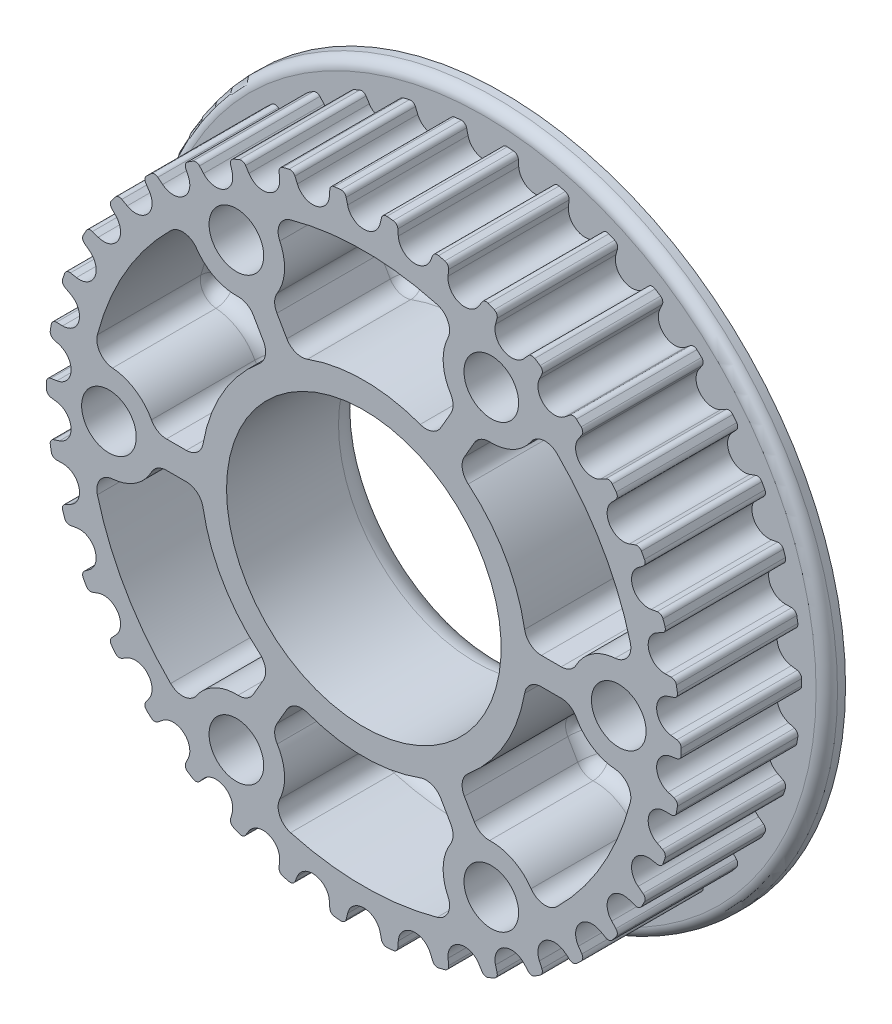
from build123d import *

# Parameters (mm, degrees)
SKETCH1_W                      = 32
SKETCH1_H                      = 1.75
BOSS_EXTRUDE1_DEPTH            = 11.25
CUT_EXTRUDE1_DEPTH             = 11.25
CUT_EXTRUDE2_DEPTH             = 11.25
CUT_EXTRUDE3_DEPTH             = 11.25
CUT_EXTRUDE4_DEPTH             = 11.25
CUT_EXTRUDE5_DEPTH             = 11.25
CUT_EXTRUDE6_DEPTH             = 11.25
F_7_0_201_DIAMETER_HOLE1_D     = 5.1054
F_7_0_201_DIAMETER_HOLE1_DEPTH = 13
HOLE1_D                        = 25.654
HOLE1_DEPTH                    = 13
FILLET1_R                      = 0.48
FILLET2_R                      = 1
FILLET3_R                      = 1.5875
FILLET4_R                      = 2.54


with BuildPart() as part:
    # Sketch1 → Revolve1 (revolve)
    with BuildSketch(Plane(origin=(0, 0, 0), x_dir=(1, 0, 0), z_dir=(0, 1, 0))):
        with Locations((16, 0.875)):
            Rectangle(SKETCH1_W, SKETCH1_H)
    revolve(axis=Axis((0, 0, -1.75), (0, 0, 1)))

    # Sketch2 → Boss-Extrude1 (add)
    with BuildSketch(Plane.XY):
        with BuildLine():
            Line((7.961201337, 28.561193485), (7.86683106, 27.588854508))
            ThreePointArc((7.86683106, 27.588854508), (8.913003864, 25.962682106), (10.737397135, 26.603387505))
            Line((10.737397135, 26.603387505), (11.260148905, 27.428662866))
            ThreePointArc((11.260148905, 27.428662866), (11.910272883, 27.152677582), (12.553638769, 26.861285406))
            Line((12.553638769, 26.861285406), (12.300513847, 25.917740702))
            ThreePointArc((12.300513847, 25.917740702), (13.064759044, 24.14155279), (14.96972661, 24.473234547))
            Line((14.96972661, 24.473234547), (15.621184585, 25.201212117))
            ThreePointArc((15.621184585, 25.201212117), (16.217016035, 24.821984025), (16.803645674, 24.428671516))
            Line((16.803645674, 24.428671516), (16.398670696, 23.539658523))
            ThreePointArc((16.398670696, 23.539658523), (16.86014167, 21.661904877), (18.793720984, 21.675515578))
            Line((18.793720984, 21.675515578), (19.556115089, 22.286338027))
            ThreePointArc((19.556115089, 22.286338027), (20.081401284, 21.81421148), (20.59529295, 21.329707178))
            Line((20.59529295, 21.329707178), (20.049514576, 20.519475852))
            ThreePointArc((20.049514576, 20.519475852), (20.195623602, 18.591376692), (22.105071664, 18.286545073))
            Line((22.105071664, 18.286545073), (22.957605776, 18.763550758))
            ThreePointArc((22.957605776, 18.763550758), (23.398018278, 18.211404137), (23.825154347, 17.648924056))
            Line((23.825154347, 17.648924056), (23.153459988, 16.939575394))
            ThreePointArc((23.153459988, 16.939575394), (22.980221594, 15.013724238), (24.813453639, 14.398765311))
            Line((24.813453639, 14.398765311), (25.732872851, 14.72894276))
            ThreePointArc((25.732872851, 14.72894276), (26.076398357, 14.111837185), (26.40512767, 13.486724314))
            Line((26.40512767, 13.486724314), (25.625839397, 12.897607499))
            ThreePointArc((25.625839397, 12.897607499), (25.137979073, 11.026536543), (26.844989313, 10.118224783))
            Line((26.844989313, 10.118224783), (27.806214267, 10.292567617))
            ThreePointArc((27.806214267, 10.292567617), (28.043482295, 9.627336119), (28.264837975, 8.956641907))
            Line((28.264837975, 8.956641907), (27.399212739, 8.503826508))
            ThreePointArc((27.399212739, 8.503826508), (26.610038043, 6.738573689), (28.144263691, 5.561685471))
            Line((28.144263691, 5.561685471), (29.121074676, 5.575438073))
            ThreePointArc((29.121074676, 5.575438073), (29.245613175, 4.880226432), (29.353557215, 4.182245667))
            Line((29.353557215, 4.182245667), (28.425207015, 3.878083308))
            ThreePointArc((28.425207015, 3.878083308), (27.356244575, 2.266800118), (28.675835956, 0.853437885))
            Line((28.675835956, 0.853437885), (29.641588117, 0.706225118))
            ThreePointArc((29.641588117, 0.706225118), (29.65, -3.105e-06), (29.641587969, -0.706231327))
            Line((29.641587969, -0.706231327), (28.675835777, -0.853443891))
            ThreePointArc((28.675835777, -0.853443891), (27.3562441, -2.266805848), (28.425206203, -3.878089261))
            Line((28.425206203, -3.878089261), (29.353556339, -4.182251815))
            ThreePointArc((29.353556339, -4.182251815), (29.245612153, -4.880232557), (29.121073509, -5.575444172))
            Line((29.121073509, -5.575444172), (28.144262526, -5.561691366))
            ThreePointArc((28.144262526, -5.561691366), (26.610036632, -6.738579262), (27.399210958, -8.503832246))
            Line((27.399210958, -8.503832246), (28.264836099, -8.956647827))
            ThreePointArc((28.264836099, -8.956647827), (28.043480279, -9.627341993), (27.806212111, -10.292573441))
            Line((27.806212111, -10.292573441), (26.844987194, -10.118230405))
            ThreePointArc((26.844987194, -10.118230405), (25.137976763, -11.026541808), (25.625836695, -12.897612866))
            Line((25.625836695, -12.897612866), (26.405124845, -13.486729844))
            ThreePointArc((26.405124845, -13.486729844), (26.076395401, -14.111842647), (25.732869766, -14.72894815))
            Line((25.732869766, -14.72894815), (24.813450624, -14.398770508))
            ThreePointArc((24.813450624, -14.398770508), (22.980218449, -15.013729051), (23.153456441, -16.939580244))
            Line((23.153456441, -16.939580244), (23.825150651, -17.648929046))
            ThreePointArc((23.825150651, -17.648929046), (23.398014464, -18.211409038), (22.957601846, -18.763555566))
            Line((22.957601846, -18.763555566), (22.105067834, -18.286549703))
            ThreePointArc((22.105067834, -18.286549703), (20.195619708, -18.591380922), (20.049510279, -20.519480051))
            Line((20.049510279, -20.519480051), (20.595288483, -21.329711491))
            ThreePointArc((20.595288483, -21.329711491), (20.081396715, -21.814215685), (19.556110421, -22.286342122))
            Line((19.556110421, -22.286342122), (18.793716444, -21.675519514))
            ThreePointArc((18.793716444, -21.675519514), (16.860137133, -21.661908408), (16.398665766, -23.539661958))
            Line((16.398665766, -23.539661958), (16.803640558, -24.428675036))
            ThreePointArc((16.803640558, -24.428675036), (16.217010836, -24.821987421), (15.621179306, -25.201215389))
            Line((15.621179306, -25.201215389), (14.969721484, -24.473237683))
            ThreePointArc((14.969721484, -24.473237683), (13.064753987, -24.141555527), (12.300508419, -25.917743278))
            Line((12.300508419, -25.917743278), (12.553633143, -26.861288035))
            ThreePointArc((12.553633143, -26.861288035), (11.910267196, -27.152680076), (11.260143161, -27.428665225))
            Line((11.260143161, -27.428665225), (10.737391563, -26.603389754))
            ThreePointArc((10.737391563, -26.603389754), (8.912998426, -25.962683972), (7.866825282, -27.588856155))
            Line((7.866825282, -27.588856155), (7.961195356, -28.561195152))
            ThreePointArc((7.961195356, -28.561195152), (7.278642529, -28.742718433), (6.591959676, -28.907932607))
            Line((6.591959676, -28.907932607), (6.212173604, -28.007870735))
            ThreePointArc((6.212173604, -28.007870735), (4.518119513, -27.07561811), (3.218555668, -28.507416989))
            Line((3.218555668, -28.507416989), (3.151596922, -29.482027353))
            ThreePointArc((3.151596922, -29.482027353), (2.448475476, -29.548730393), (1.743964724, -29.598666981))
            Line((1.743964724, -29.598666981), (1.51750375, -28.648370047))
            ThreePointArc((1.51750375, -28.648370047), (-1.916e-06, -27.45), (-1.51750775, -28.648369835))
            Line((-1.51750775, -28.648369835), (-1.743968856, -29.598666737))
            ThreePointArc((-1.743968856, -29.598666737), (-2.448479602, -29.548730051), (-3.151601038, -29.482026913))
            Line((-3.151601038, -29.482026913), (-3.218559649, -28.50741654))
            ThreePointArc((-3.218559649, -28.50741654), (-4.518123294, -27.07561748), (-6.212177514, -28.007869867))
            Line((-6.212177514, -28.007869867), (-6.591963712, -28.907931687))
            ThreePointArc((-6.591963712, -28.907931687), (-7.278646542, -28.742717417), (-7.961199344, -28.56119404))
            Line((-7.961199344, -28.56119404), (-7.866829134, -27.588855057))
            ThreePointArc((-7.866829134, -27.588855057), (-8.913002051, -25.962682728), (-10.737395278, -26.603388255))
            Line((-10.737395278, -26.603388255), (-11.26014699, -27.428663652))
            ThreePointArc((-11.26014699, -27.428663652), (-11.910270987, -27.152678413), (-12.553636893, -26.861286282))
            Line((-12.553636893, -26.861286282), (-12.300512038, -25.91774156))
            ThreePointArc((-12.300512038, -25.91774156), (-13.064757358, -24.141553703), (-14.969724901, -24.473235592))
            Line((-14.969724901, -24.473235592), (-15.621182825, -25.201213208))
            ThreePointArc((-15.621182825, -25.201213208), (-16.217014302, -24.821985157), (-16.803643969, -24.428672689))
            Line((-16.803643969, -24.428672689), (-16.398669053, -23.539659668))
            ThreePointArc((-16.398669053, -23.539659668), (-16.860140157, -21.661906054), (-18.793719471, -21.67551689))
            Line((-18.793719471, -21.67551689), (-19.556113533, -22.286339392))
            ThreePointArc((-19.556113533, -22.286339392), (-20.081399761, -21.814212882), (-20.595291461, -21.329708616))
            Line((-20.595291461, -21.329708616), (-20.049513144, -20.519477251))
            ThreePointArc((-20.049513144, -20.519477251), (-20.195622304, -18.591378102), (-22.105070387, -18.286546616))
            Line((-22.105070387, -18.286546616), (-22.957604466, -18.763552361))
            ThreePointArc((-22.957604466, -18.763552361), (-23.398017007, -18.211405771), (-23.825153115, -17.648925719))
            Line((-23.825153115, -17.648925719), (-23.153458806, -16.939577011))
            ThreePointArc((-23.153458806, -16.939577011), (-22.980220545, -15.013725843), (-24.813452634, -14.398767043))
            Line((-24.813452634, -14.398767043), (-25.732871823, -14.728944557))
            ThreePointArc((-25.732871823, -14.728944557), (-26.076397371, -14.111839006), (-26.405126729, -13.486726158))
            Line((-26.405126729, -13.486726158), (-25.625838496, -12.897609288))
            ThreePointArc((-25.625838496, -12.897609288), (-25.137978303, -11.026538298), (-26.844988607, -10.118226657))
            Line((-26.844988607, -10.118226657), (-27.806213548, -10.292569558))
            ThreePointArc((-27.806213548, -10.292569558), (-28.043481623, -9.627338077), (-28.26483735, -8.95664388))
            Line((-28.26483735, -8.95664388), (-27.399212145, -8.503828421))
            ThreePointArc((-27.399212145, -8.503828421), (-26.610037572, -6.738575546), (-28.144263303, -5.561687436))
            Line((-28.144263303, -5.561687436), (-29.121074287, -5.575440106))
            ThreePointArc((-29.121074287, -5.575440106), (-29.245612834, -4.880228474), (-29.353556923, -4.182247717))
            Line((-29.353556923, -4.182247717), (-28.425206744, -3.878085292))
            ThreePointArc((-28.425206744, -3.878085292), (-27.356244416, -2.266802028), (-28.675835896, -0.853439887))
            Line((-28.675835896, -0.853439887), (-29.641588067, -0.706227188))
            ThreePointArc((-29.641588067, -0.706227188), (-29.65, 1.035e-06), (-29.641588018, 0.706229257))
            Line((-29.641588018, 0.706229257), (-28.675835836, 0.853441889))
            ThreePointArc((-28.675835836, 0.853441889), (-27.356244258, 2.266803938), (-28.425206473, 3.878087277))
            Line((-28.425206473, 3.878087277), (-29.353556631, 4.182249766))
            ThreePointArc((-29.353556631, 4.182249766), (-29.245612493, 4.880230515), (-29.121073898, 5.575442139))
            Line((-29.121073898, 5.575442139), (-28.144262914, 5.561689401))
            ThreePointArc((-28.144262914, 5.561689401), (-26.610037102, 6.738577404), (-27.399211551, 8.503830333))
            Line((-27.399211551, 8.503830333), (-28.264836724, 8.956645853))
            ThreePointArc((-28.264836724, 8.956645853), (-28.043480951, 9.627340035), (-27.80621283, 10.2925715))
            Line((-27.80621283, 10.2925715), (-26.8449879, 10.118228531))
            ThreePointArc((-26.8449879, 10.118228531), (-25.137977533, 11.026540053), (-25.625837596, 12.897611077))
            Line((-25.625837596, 12.897611077), (-26.405125787, 13.486728001))
            ThreePointArc((-26.405125787, 13.486728001), (-26.076396386, 14.111840826), (-25.732870795, 14.728946353))
            Line((-25.732870795, 14.728946353), (-24.813451629, 14.398768775))
            ThreePointArc((-24.813451629, 14.398768775), (-22.980219497, 15.013727447), (-23.153457623, 16.939578627))
            Line((-23.153457623, 16.939578627), (-23.825151883, 17.648927382))
            ThreePointArc((-23.825151883, 17.648927382), (-23.398015736, 18.211407404), (-22.957603156, 18.763553963))
            Line((-22.957603156, 18.763553963), (-22.105069111, 18.28654816))
            ThreePointArc((-22.105069111, 18.28654816), (-20.195621006, 18.591379512), (-20.049511711, 20.519478651))
            Line((-20.049511711, 20.519478651), (-20.595289972, 21.329710053))
            ThreePointArc((-20.595289972, 21.329710053), (-20.081398238, 21.814214284), (-19.556111977, 22.286340757))
            Line((-19.556111977, 22.286340757), (-18.793717957, 21.675518202))
            ThreePointArc((-18.793717957, 21.675518202), (-16.860138645, 21.661907231), (-16.398667409, 23.539660813))
            Line((-16.398667409, 23.539660813), (-16.803642264, 24.428673862))
            ThreePointArc((-16.803642264, 24.428673862), (-16.217012569, 24.821986289), (-15.621181066, 25.201214298))
            Line((-15.621181066, 25.201214298), (-14.969723193, 24.473236637))
            ThreePointArc((-14.969723193, 24.473236637), (-13.064755673, 24.141554615), (-12.300510228, 25.917742419))
            Line((-12.300510228, 25.917742419), (-12.553635018, 26.861287159))
            ThreePointArc((-12.553635018, 26.861287159), (-11.910269092, 27.152679245), (-11.260145076, 27.428664438))
            Line((-11.260145076, 27.428664438), (-10.73739342, 26.603389004))
            ThreePointArc((-10.73739342, 26.603389004), (-8.913000239, 25.96268335), (-7.866827208, 27.588855606))
            Line((-7.866827208, 27.588855606), (-7.96119735, 28.561194596))
            ThreePointArc((-7.96119735, 28.561194596), (-7.278644535, 28.742717925), (-6.591961694, 28.907932147))
            Line((-6.591961694, 28.907932147), (-6.212175559, 28.007870301))
            ThreePointArc((-6.212175559, 28.007870301), (-4.518121404, 27.075617795), (-3.218557659, 28.507416764))
            Line((-3.218557659, 28.507416764), (-3.15159898, 29.482027133))
            ThreePointArc((-3.15159898, 29.482027133), (-2.448477539, 29.548730222), (-1.74396679, 29.598666859))
            Line((-1.74396679, 29.598666859), (-1.51750575, 28.648369941))
            ThreePointArc((-1.51750575, 28.648369941), (0, 27.45), (1.51750575, 28.648369941))
            Line((1.51750575, 28.648369941), (1.74396679, 29.598666859))
            ThreePointArc((1.74396679, 29.598666859), (2.448479602, 29.548730051), (3.151603097, 29.482026693))
            Line((3.151603097, 29.482026693), (3.218561639, 28.507416315))
            ThreePointArc((3.218561639, 28.507416315), (4.518125184, 27.075617164), (6.21217947, 28.007869434))
            Line((6.21217947, 28.007869434), (6.591965731, 28.907931227))
            ThreePointArc((6.591965731, 28.907931227), (7.278648549, 28.742716909), (7.961201337, 28.561193485))
        make_face()
    extrude(amount=BOSS_EXTRUDE1_DEPTH)

    # Sketch3 → Cut-Extrude1 (cut)
    with BuildSketch(Plane.XY.offset(11.25)):
        with BuildLine():
            Line((-10.84756688, -16.248536974), (-8.693347835, -12.517320138))
            ThreePointArc((-8.693347835, -12.517320138), (-13.198227154, -7.62), (-15.186991144, -1.27))
            Line((-15.186991144, -1.27), (-19.495429234, -1.27))
            ThreePointArc((-19.495429234, -1.27), (-21.791343481, -4.020562936), (-25.36850315, -4.222422788))
            ThreePointArc((-25.36850315, -4.222422788), (-22.272008322, -12.85875), (-16.340976975, -19.85855679))
            ThreePointArc((-16.340976975, -19.85855679), (-14.377581381, -16.861575569), (-10.84756688, -16.248536974))
        make_face()
    extrude(amount=-CUT_EXTRUDE1_DEPTH, mode=Mode.SUBTRACT)

    # Sketch4 → Cut-Extrude2 (cut)
    with BuildSketch(Plane.XY.offset(11.25)):
        with BuildLine():
            Line((8.647862354, -17.518536974), (6.493643309, -13.787320138))
            ThreePointArc((6.493643309, -13.787320138), (0, -15.24), (-6.493643309, -13.787320138))
            Line((-6.493643309, -13.787320138), (-8.647862354, -17.518536974))
            ThreePointArc((-8.647862354, -17.518536974), (-7.4137621, -20.882138505), (-9.027526175, -24.080979577))
            ThreePointArc((-9.027526175, -24.080979577), (0, -25.7175), (9.027526175, -24.080979577))
            ThreePointArc((9.027526175, -24.080979577), (7.4137621, -20.882138505), (8.647862354, -17.518536974))
        make_face()
    extrude(amount=-CUT_EXTRUDE2_DEPTH, mode=Mode.SUBTRACT)

    # Sketch5 → Cut-Extrude3 (cut)
    with BuildSketch(Plane.XY.offset(11.25)):
        with BuildLine():
            Line((8.693347835, -12.517320138), (10.84756688, -16.248536974))
            ThreePointArc((10.84756688, -16.248536974), (14.377581381, -16.861575569), (16.340976975, -19.85855679))
            ThreePointArc((16.340976975, -19.85855679), (22.272008322, -12.85875), (25.36850315, -4.222422788))
            ThreePointArc((25.36850315, -4.222422788), (21.791343481, -4.020562936), (19.495429234, -1.27))
            Line((19.495429234, -1.27), (15.186991144, -1.27))
            ThreePointArc((15.186991144, -1.27), (13.198227154, -7.62), (8.693347835, -12.517320138))
        make_face()
    extrude(amount=-CUT_EXTRUDE3_DEPTH, mode=Mode.SUBTRACT)

    # Sketch6 → Cut-Extrude4 (cut)
    with BuildSketch(Plane.XY.offset(11.25)):
        with BuildLine():
            Line((15.186991144, 1.27), (19.495429234, 1.27))
            ThreePointArc((19.495429234, 1.27), (21.791343481, 4.020562936), (25.36850315, 4.222422788))
            ThreePointArc((25.36850315, 4.222422788), (22.272008322, 12.85875), (16.340976975, 19.85855679))
            ThreePointArc((16.340976975, 19.85855679), (14.377581381, 16.861575569), (10.84756688, 16.248536974))
            Line((10.84756688, 16.248536974), (8.693347835, 12.517320138))
            ThreePointArc((8.693347835, 12.517320138), (13.198227154, 7.62), (15.186991144, 1.27))
        make_face()
    extrude(amount=-CUT_EXTRUDE4_DEPTH, mode=Mode.SUBTRACT)

    # Sketch7 → Cut-Extrude5 (cut)
    with BuildSketch(Plane.XY.offset(11.25)):
        with BuildLine():
            Line((6.493643309, 13.787320138), (8.647862354, 17.518536974))
            ThreePointArc((8.647862354, 17.518536974), (7.4137621, 20.882138505), (9.027526175, 24.080979577))
            ThreePointArc((9.027526175, 24.080979577), (0, 25.7175), (-9.027526175, 24.080979577))
            ThreePointArc((-9.027526175, 24.080979577), (-7.4137621, 20.882138505), (-8.647862354, 17.518536974))
            Line((-8.647862354, 17.518536974), (-6.493643309, 13.787320138))
            ThreePointArc((-6.493643309, 13.787320138), (0, 15.24), (6.493643309, 13.787320138))
        make_face()
    extrude(amount=-CUT_EXTRUDE5_DEPTH, mode=Mode.SUBTRACT)

    # Sketch8 → Cut-Extrude6 (cut)
    with BuildSketch(Plane.XY.offset(11.25)):
        with BuildLine():
            Line((-19.495429234, 1.27), (-15.186991144, 1.27))
            ThreePointArc((-15.186991144, 1.27), (-13.198227154, 7.62), (-8.693347835, 12.517320138))
            Line((-8.693347835, 12.517320138), (-10.84756688, 16.248536974))
            ThreePointArc((-10.84756688, 16.248536974), (-14.377581381, 16.861575569), (-16.340976975, 19.85855679))
            ThreePointArc((-16.340976975, 19.85855679), (-22.272008322, 12.85875), (-25.36850315, 4.222422788))
            ThreePointArc((-25.36850315, 4.222422788), (-21.791343481, 4.020562936), (-19.495429234, 1.27))
        make_face()
    extrude(amount=-CUT_EXTRUDE6_DEPTH, mode=Mode.SUBTRACT)

    # #7 (0.201) Diameter Hole1
    with Locations(Plane.XY.offset(11.25)):
        with Locations((23.8125, 0), (11.90625, 20.622229928), (-11.90625, 20.622229928), (-23.8125, 0), (-11.90625, -20.622229928), (11.90625, -20.622229928)):
            Hole(F_7_0_201_DIAMETER_HOLE1_D / 2, depth=F_7_0_201_DIAMETER_HOLE1_DEPTH)

    # Hole1
    with Locations(Plane(origin=(0, 0, -1.75), x_dir=(-1, 0, 0), z_dir=(0, 0, -1))):
        with Locations((0, 0)):
            Hole(HOLE1_D / 2, depth=HOLE1_DEPTH)

    # Fillet1
    fillet1_edges = [part.edges().sort_by_distance(p)[0] for p in [
        (-7.961199344, -28.56119404, 5.625),
        (-6.591963712, -28.907931687, 5.625),
        (-3.151601038, -29.482026913, 5.625),
        (-1.743968856, -29.598666737, 5.625),
        (1.743964724, -29.598666981, 5.625),
        (3.151596922, -29.482027353, 5.625),
        (6.591959676, -28.907932607, 5.625),
        (7.961195356, -28.561195152, 5.625),
        (11.260143161, -27.428665225, 5.625),
        (12.553633143, -26.861288035, 5.625),
        (15.621179306, -25.201215389, 5.625),
        (16.803640558, -24.428675036, 5.625),
        (19.556110421, -22.286342122, 5.625),
        (20.595288483, -21.329711491, 5.625),
        (22.957601846, -18.763555566, 5.625),
        (23.825150651, -17.648929046, 5.625),
        (25.732869766, -14.72894815, 5.625),
        (26.405124845, -13.486729844, 5.625),
        (27.806212111, -10.292573441, 5.625),
        (28.264836099, -8.956647827, 5.625),
        (29.121073509, -5.575444172, 5.625),
        (29.353556339, -4.182251815, 5.625),
        (29.641587969, -0.706231327, 5.625),
        (29.641588117, 0.706225118, 5.625),
        (29.353557215, 4.182245667, 5.625),
        (29.121074676, 5.575438073, 5.625),
        (28.264837975, 8.956641907, 5.625),
        (27.806214267, 10.292567617, 5.625),
        (26.40512767, 13.486724314, 5.625),
        (25.732872851, 14.72894276, 5.625),
        (23.825154347, 17.648924056, 5.625),
        (22.957605776, 18.763550758, 5.625),
        (20.59529295, 21.329707178, 5.625),
        (19.556115089, 22.286338027, 5.625),
        (16.803645674, 24.428671516, 5.625),
        (15.621184585, 25.201212117, 5.625),
        (12.553638769, 26.861285406, 5.625),
        (11.260148905, 27.428662866, 5.625),
        (7.961201337, 28.561193485, 5.625),
        (6.591965731, 28.907931227, 5.625),
        (3.151603097, 29.482026693, 5.625),
        (1.74396679, 29.598666859, 5.625),
        (-1.74396679, 29.598666859, 5.625),
        (-3.15159898, 29.482027133, 5.625),
        (-6.591961694, 28.907932147, 5.625),
        (-7.96119735, 28.561194596, 5.625),
        (-11.260145076, 27.428664438, 5.625),
        (-12.553635018, 26.861287159, 5.625),
        (-15.621181066, 25.201214298, 5.625),
        (-16.803642264, 24.428673862, 5.625),
        (-19.556111977, 22.286340757, 5.625),
        (-20.595289972, 21.329710053, 5.625),
        (-22.957603156, 18.763553963, 5.625),
        (-23.825151883, 17.648927382, 5.625),
        (-25.732870795, 14.728946353, 5.625),
        (-26.405125787, 13.486728001, 5.625),
        (-27.80621283, 10.2925715, 5.625),
        (-28.264836724, 8.956645853, 5.625),
        (-29.121073898, 5.575442139, 5.625),
        (-29.353556631, 4.182249766, 5.625),
        (-29.641588018, 0.706229257, 5.625),
        (-29.641588067, -0.706227188, 5.625),
        (-29.353556923, -4.182247717, 5.625),
        (-29.121074287, -5.575440106, 5.625),
        (-28.26483735, -8.95664388, 5.625),
        (-27.806213548, -10.292569558, 5.625),
        (-26.405126729, -13.486726158, 5.625),
        (-25.732871823, -14.728944557, 5.625),
        (-23.825153115, -17.648925719, 5.625),
        (-22.957604466, -18.763552361, 5.625),
        (-20.595291461, -21.329708616, 5.625),
        (-19.556113533, -22.286339392, 5.625),
        (-16.803643969, -24.428672689, 5.625),
        (-15.621182825, -25.201213208, 5.625),
        (-12.553636893, -26.861286282, 5.625),
        (-11.26014699, -27.428663652, 5.625),
    ]]
    fillet(fillet1_edges, radius=FILLET1_R)

    # Fillet2
    fillet2_edges = [part.edges().sort_by_distance(p)[0] for p in [
        (-32, 0, 0),
    ]]
    fillet(fillet2_edges, radius=FILLET2_R)

    # Fillet3
    fillet3_edges = [part.edges().sort_by_distance(p)[0] for p in [
        (-14.377581381, -16.861575569, 0),
        (-10.84756688, -16.248536974, 5.625),
        (-22.272008322, -12.85875, 0),
        (-16.340976975, -19.85855679, 5.625),
        (-21.791343481, -4.020562936, 0),
        (-25.36850315, -4.222422788, 5.625),
        (-17.341210189, -1.27, 0),
        (-19.495429234, -1.27, 5.625),
        (-13.198227154, -7.62, 0),
        (-15.186991144, -1.27, 5.625),
        (-9.770457357, -14.382928556, 0),
        (-8.693347835, -12.517320138, 5.625),
        (7.4137621, -20.882138505, 0),
        (8.647862354, -17.518536974, 5.625),
        (0, -25.7175, 0),
        (9.027526175, -24.080979577, 5.625),
        (-7.4137621, -20.882138505, 0),
        (-9.027526175, -24.080979577, 5.625),
        (-7.570752832, -15.652928556, 0),
        (-8.647862354, -17.518536974, 5.625),
        (0, -15.24, 0),
        (-6.493643309, -13.787320138, 5.625),
        (7.570752832, -15.652928556, 0),
        (6.493643309, -13.787320138, 5.625),
        (13.198227154, -7.62, 0),
        (8.693347835, -12.517320138, 5.625),
        (17.341210189, -1.27, 0),
        (15.186991144, -1.27, 5.625),
        (21.791343481, -4.020562936, 0),
        (19.495429234, -1.27, 5.625),
        (22.272008322, -12.85875, 0),
        (25.36850315, -4.222422788, 5.625),
        (14.377581381, -16.861575569, 0),
        (16.340976975, -19.85855679, 5.625),
        (9.770457357, -14.382928556, 0),
        (10.84756688, -16.248536974, 5.625),
        (13.198227154, 7.62, 0),
        (15.186991144, 1.27, 5.625),
        (9.770457357, 14.382928556, 0),
        (8.693347835, 12.517320138, 5.625),
        (14.377581381, 16.861575569, 0),
        (10.84756688, 16.248536974, 5.625),
        (22.272008322, 12.85875, 0),
        (16.340976975, 19.85855679, 5.625),
        (21.791343481, 4.020562936, 0),
        (25.36850315, 4.222422788, 5.625),
        (17.341210189, 1.27, 0),
        (19.495429234, 1.27, 5.625),
        (0, 15.24, 0),
        (6.493643309, 13.787320138, 5.625),
        (-7.570752832, 15.652928556, 0),
        (-6.493643309, 13.787320138, 5.625),
        (-7.4137621, 20.882138505, 0),
        (-8.647862354, 17.518536974, 5.625),
        (0, 25.7175, 0),
        (-9.027526175, 24.080979577, 5.625),
        (7.4137621, 20.882138505, 0),
        (9.027526175, 24.080979577, 5.625),
        (7.570752832, 15.652928556, 0),
        (8.647862354, 17.518536974, 5.625),
        (-21.791343481, 4.020562936, 0),
        (-19.495429234, 1.27, 5.625),
        (-22.272008322, 12.85875, 0),
        (-25.36850315, 4.222422788, 5.625),
        (-14.377581381, 16.861575569, 0),
        (-16.340976975, 19.85855679, 5.625),
        (-9.770457357, 14.382928556, 0),
        (-10.84756688, 16.248536974, 5.625),
        (-13.198227154, 7.62, 0),
        (-8.693347835, 12.517320138, 5.625),
        (-17.341210189, 1.27, 0),
        (-15.186991144, 1.27, 5.625),
    ]]
    fillet(fillet3_edges, radius=FILLET3_R)

    # Fillet4
    fillet4_edges = [part.edges().sort_by_distance(p)[0] for p in [
        (-12.827, 0, -1.75),
    ]]
    fillet(fillet4_edges, radius=FILLET4_R)


solid = part.part
